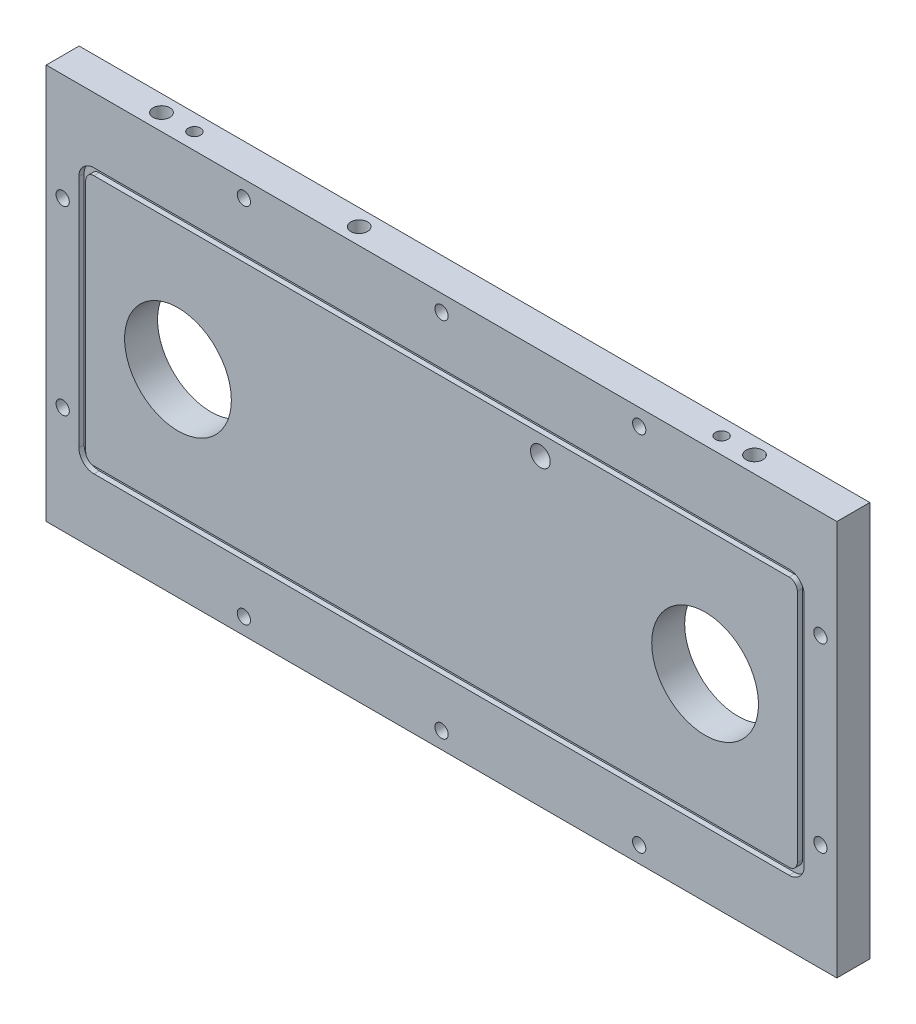
from build123d import *

# Parameters (mm, degrees)
SKETCH1_W                                           = 304.8
SKETCH1_H                                           = 152.4
BOSS_EXTRUDE1_DEPTH                                 = 12.7
SKETCH2_W                                           = 279.6032
SKETCH2_H                                           = 102.1842
CUT_EXTRUDE1_DEPTH                                  = 2.032
SKETCH3_W                                           = 274.32
SKETCH3_H                                           = 96.901
BOSS_EXTRUDE2_DEPTH                                 = 2.032
M36_CLEARANCE_HOLE1_D                               = 41.148
M36_CLEARANCE_HOLE1_DEPTH                           = 12.7
M7_CLEARANCE_HOLE1_D                                = 7.62
M36_CLEARANCE_HOLE2_D                               = 41.148
M36_CLEARANCE_HOLE2_DEPTH                           = 12.7
M3_5_CLEARANCE_HOLE2_D                              = 3.7973
M3_5_CLEARANCE_HOLE2_DEPTH                          = 7.874
M3_5_CLEARANCE_HOLE2_TIP                            = 1.140824014
CBORE_FOR_10_BINDING_HEAD_MACHINE_SCREW_D           = 5.1054
CBORE_FOR_10_BINDING_HEAD_MACHINE_SCREW_CBORE_D     = 11.1125
CBORE_FOR_10_BINDING_HEAD_MACHINE_SCREW_CBORE_DEPTH = 3.1242
M4_CLEARANCE_HOLE1_D                                = 4.7625
M4_CLEARANCE_HOLE1_DEPTH                            = 12.7
M4_CLEARANCE_HOLE1_TIP                              = 1.430799349
M4_CLEARANCE_HOLE2_D                                = 4.7625
M4_CLEARANCE_HOLE2_DEPTH                            = 12.7
M4_CLEARANCE_HOLE2_TIP                              = 1.430799349
FILLET1_R                                           = 3.175
FILLET2_R                                           = 5.8166
MIRROR2_COPY_1_D                                    = 5.1054
MIRROR2_COPY_1_CBORE_D                              = 11.1125
MIRROR2_COPY_1_CBORE_DEPTH                          = 3.1242
CIRPATTERN1_COUNT                                   = 6
SKETCH22_R                                          = 3.2385
CUT_EXTRUDE2_DEPTH                                  = 76.2
SKETCH23_R                                          = 3.2385
CUT_EXTRUDE3_DEPTH                                  = 50.8
MIRROR6_COPY_1_SKETCH_R                             = 3.2385
MIRROR6_COPY_1_DEPTH                                = 50.8
SKETCH24_R                                          = 3.2385
CUT_EXTRUDE4_DEPTH                                  = 76.2


with BuildPart() as part:
    # Sketch1 → Boss-Extrude1 (new body)
    with BuildSketch(Plane.XY.offset(12.7)):
        Rectangle(SKETCH1_W, SKETCH1_H)
    extrude(amount=-BOSS_EXTRUDE1_DEPTH)

    # Sketch2 → Cut-Extrude1 (cut)
    with BuildSketch(Plane.XY.offset(12.7)):
        Rectangle(SKETCH2_W, SKETCH2_H)
    extrude(amount=-CUT_EXTRUDE1_DEPTH, mode=Mode.SUBTRACT)

    # Sketch3 → Boss-Extrude2 (add)
    with BuildSketch(Plane.XY.offset(10.668)):
        Rectangle(SKETCH3_W, SKETCH3_H)
    extrude(amount=BOSS_EXTRUDE2_DEPTH)

    # M36 Clearance Hole1
    with Locations(Plane(origin=(0, 0, 0), x_dir=(-1, 0, 0), z_dir=(0, 0, -1))):
        with Locations((-101.6, 0)):
            Hole(M36_CLEARANCE_HOLE1_D / 2, depth=M36_CLEARANCE_HOLE1_DEPTH)

    # M7 Clearance Hole1 (through all)
    with Locations(Plane(origin=(0, 0, 0), x_dir=(-1, 0, 0), z_dir=(0, 0, -1))):
        with Locations((-38.1, 40.8686)):
            Hole(M7_CLEARANCE_HOLE1_D / 2)

    # M36 Clearance Hole2
    with Locations(Plane.XY.offset(12.7)):
        with Locations((-101.6, 0)):
            Hole(M36_CLEARANCE_HOLE2_D / 2, depth=M36_CLEARANCE_HOLE2_DEPTH)

    # M3.5 Clearance Hole2
    with Locations(Plane(origin=(0, 0, 0), x_dir=(-1, 0, 0), z_dir=(0, 0, -1))):
        with Locations((-74.763604788, -15.494), (-101.6, -30.988), (-101.6, 30.988), (-128.436395212, 15.494), (-128.436395212, -15.494), (-74.763604788, 15.494), (101.6, 30.988), (128.436395212, 15.494), (128.436395212, -15.494), (101.6, -30.988), (74.763604788, -15.494), (74.763604788, 15.494)):
            Hole(M3_5_CLEARANCE_HOLE2_D / 2, depth=M3_5_CLEARANCE_HOLE2_DEPTH)
            with Locations((0, 0, -(M3_5_CLEARANCE_HOLE2_DEPTH + M3_5_CLEARANCE_HOLE2_TIP / 2))):  # 118° drill point
                Cone(0, M3_5_CLEARANCE_HOLE2_D / 2, M3_5_CLEARANCE_HOLE2_TIP, mode=Mode.SUBTRACT)

    # CBORE for #10 Binding Head Machine Screw1 (through all)
    with Locations(Plane(origin=(0, 0, 0), x_dir=(-1, 0, 0), z_dir=(0, 0, -1))):
        with Locations((0, 69.85), (-76.2, 69.85), (-146.05, 34.925)):
            cbore_for_10_binding_head_machine_screw = CounterBoreHole(CBORE_FOR_10_BINDING_HEAD_MACHINE_SCREW_D / 2, CBORE_FOR_10_BINDING_HEAD_MACHINE_SCREW_CBORE_D / 2, CBORE_FOR_10_BINDING_HEAD_MACHINE_SCREW_CBORE_DEPTH)

    # M4 Clearance Hole1
    with Locations(Plane(origin=(0, 76.2, 0), x_dir=(1, 0, 0), z_dir=(0, 1, 0))):
        with Locations((101.6, -6.35), (-101.6, -6.35)):
            Hole(M4_CLEARANCE_HOLE1_D / 2, depth=M4_CLEARANCE_HOLE1_DEPTH)
            with Locations((0, 0, -(M4_CLEARANCE_HOLE1_DEPTH + M4_CLEARANCE_HOLE1_TIP / 2))):  # 118° drill point
                Cone(0, M4_CLEARANCE_HOLE1_D / 2, M4_CLEARANCE_HOLE1_TIP, mode=Mode.SUBTRACT)

    # M4 Clearance Hole2
    with Locations(Plane(origin=(0, -76.2, 0), x_dir=(-1, 0, 0), z_dir=(0, -1, 0))):
        with Locations((101.6, -6.35), (-101.6, -6.35)):
            Hole(M4_CLEARANCE_HOLE2_D / 2, depth=M4_CLEARANCE_HOLE2_DEPTH)
            with Locations((0, 0, -(M4_CLEARANCE_HOLE2_DEPTH + M4_CLEARANCE_HOLE2_TIP / 2))):  # 118° drill point
                Cone(0, M4_CLEARANCE_HOLE2_D / 2, M4_CLEARANCE_HOLE2_TIP, mode=Mode.SUBTRACT)

    # Fillet1
    fillet1_edges = [part.edges().sort_by_distance(p)[0] for p in [
        (137.16, 48.4505, 11.684),
        (-137.16, 48.4505, 11.684),
        (-137.16, -48.4505, 11.684),
        (137.16, -48.4505, 11.684),
    ]]
    fillet(fillet1_edges, radius=FILLET1_R)

    # Fillet2
    fillet2_edges = [part.edges().sort_by_distance(p)[0] for p in [
        (-139.8016, -51.0921, 11.684),
        (-139.8016, 51.0921, 11.684),
        (139.8016, 51.0921, 11.684),
        (139.8016, -51.0921, 11.684),
    ]]
    fillet(fillet2_edges, radius=FILLET2_R)

    # Mirror1: CBORE for #10 Binding Head Machine Screw1 across plane
    add(cbore_for_10_binding_head_machine_screw.mirror(Plane(origin=(0, 0, 0), x_dir=(0, 0, 1), z_dir=(1, 0, 0))), mode=Mode.SUBTRACT)

    # Mirror2: CBORE for #10 Binding Head Machine Screw1 across plane
    add(cbore_for_10_binding_head_machine_screw.mirror(Plane.ZX), mode=Mode.SUBTRACT)

    # Mirror2 copy 1 (through all)
    with Locations(Plane(origin=(0, 0, 0), x_dir=(1, 0, 0), z_dir=(0, 0, -1))):
        with Locations((0, 69.85), (-76.2, 69.85), (-146.05, 34.925)):
            CounterBoreHole(MIRROR2_COPY_1_D / 2, MIRROR2_COPY_1_CBORE_D / 2, MIRROR2_COPY_1_CBORE_DEPTH)

    # Sketch20 → #10-24 Tapped Hole1 (revolve, cut)
    with BuildSketch(Plane(origin=(38.1, 59.868562, 0), x_dir=(0, 1, 0), z_dir=(1, 0, 0))):
        Polygon((0, 0), (0, 8.890364014), (1.89865, 7.74954), (1.89865, 0), align=None)
    f_10_24_tapped_hole1 = revolve(axis=Axis((38.1, 59.868562, -6.35), (0, 0, 1)), mode=Mode.SUBTRACT)

    # CirPattern1: #10-24 Tapped Hole1 ×6 about axis
    cirpattern1_axis = Axis((38.1, 40.8686, 0), (0, 0, 1))
    for i in range(1, CIRPATTERN1_COUNT):
        add(f_10_24_tapped_hole1.rotate(cirpattern1_axis, i * 360 / CIRPATTERN1_COUNT), mode=Mode.SUBTRACT)

    # Sketch22 → Cut-Extrude2 (cut)
    with BuildSketch(Plane(origin=(0, 76.2, 0), x_dir=(1, 0, 0), z_dir=(0, 1, 0))):
        with Locations((-38.1, -6.35)):
            Circle(SKETCH22_R)
    extrude(amount=-CUT_EXTRUDE2_DEPTH, mode=Mode.SUBTRACT)

    # Sketch23 → Cut-Extrude3 (cut)
    with BuildSketch(Plane(origin=(0, 76.2, 0), x_dir=(1, 0, 0), z_dir=(0, 1, 0))):
        with Locations((-114.3, -6.35)):
            Circle(SKETCH23_R)
    cut_extrude3 = extrude(amount=-CUT_EXTRUDE3_DEPTH, mode=Mode.SUBTRACT)

    # Mirror5: Cut-Extrude3 across plane
    add(cut_extrude3.mirror(Plane.ZX), mode=Mode.SUBTRACT)

    # Mirror6: Cut-Extrude3 across plane
    add(cut_extrude3.mirror(Plane(origin=(0, 0, 0), x_dir=(0, 0, 1), z_dir=(1, 0, 0))), mode=Mode.SUBTRACT)

    # Mirror6 copy 1 sketch → Mirror6 copy 1 (cut)
    with BuildSketch(Plane(origin=(0, -76.2, 0), x_dir=(-1, 0, 0), z_dir=(0, -1, 0))):
        with Locations((-114.3, -6.35)):
            Circle(MIRROR6_COPY_1_SKETCH_R)
    extrude(amount=-MIRROR6_COPY_1_DEPTH, mode=Mode.SUBTRACT)

    # Sketch24 → Cut-Extrude4 (cut)
    with BuildSketch(Plane.XZ.offset(76.2)):
        with Locations((38.1, 6.35)):
            Circle(SKETCH24_R)
    extrude(amount=-CUT_EXTRUDE4_DEPTH, mode=Mode.SUBTRACT)


solid = part.part
